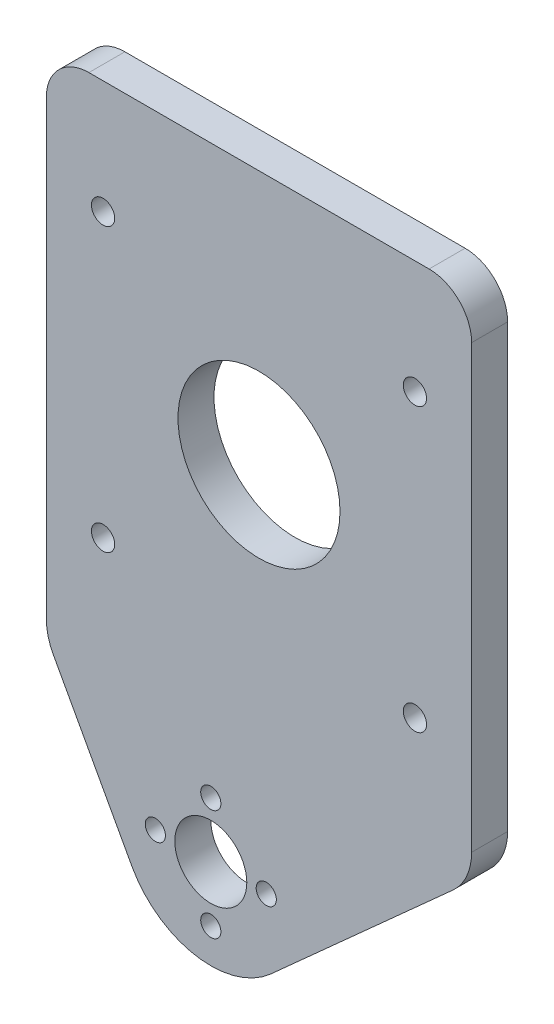
from build123d import *

# Parameters (mm, degrees)
SKETCH1_W           = 304.8
SKETCH1_H           = 89.8
SKETCH1_R           = 14.2875
SKETCH1_R_2         = 2.54
SKETCH1_R_3         = 17.145
BOSS_EXTRUDE1_DEPTH = 6.35
SKETCH2_W           = 114.9
SKETCH2_H           = 89.8
SKETCH2_R           = 2.54
SKETCH2_R_2         = 17.145
CUT_EXTRUDE1_DEPTH  = 10
SKETCH4_R           = 6.35
SKETCH4_R_2         = 1.778
BOSS_EXTRUDE2_DEPTH = 6.35
FILLET1_R           = 10
FILLET2_R           = 7.5
SKETCH7_R           = 2.05
CUT_EXTRUDE2_DEPTH  = 10


with BuildPart() as part:
    # Sketch1 → Boss-Extrude1 (new body)
    with BuildSketch(Plane.XY):
        with Locations((152.4, 44.9)):
            Rectangle(SKETCH1_W, SKETCH1_H)
        with Locations((152.4, 44.9)):
            Circle(SKETCH1_R, mode=Mode.SUBTRACT)
        with Locations((109.401585406, 62.859439014)):
            Circle(SKETCH1_R_2, mode=Mode.SUBTRACT)
        with Locations((109.399439014, 26.938414594)):
            Circle(SKETCH1_R_2, mode=Mode.SUBTRACT)
        with Locations((73.478414594, 26.940560986)):
            Circle(SKETCH1_R_2, mode=Mode.SUBTRACT)
        with Locations((73.480560986, 62.861585406)):
            Circle(SKETCH1_R_2, mode=Mode.SUBTRACT)
        with Locations((91.44, 44.9)):
            Circle(SKETCH1_R_3, mode=Mode.SUBTRACT)
        with Locations((195.400560986, 62.861585406)):
            Circle(SKETCH1_R_2, mode=Mode.SUBTRACT)
        with Locations((231.321585406, 62.859439014)):
            Circle(SKETCH1_R_2, mode=Mode.SUBTRACT)
        with Locations((231.319439014, 26.938414594)):
            Circle(SKETCH1_R_2, mode=Mode.SUBTRACT)
        with Locations((195.398414594, 26.940560986)):
            Circle(SKETCH1_R_2, mode=Mode.SUBTRACT)
        with Locations((213.36, 44.9)):
            Circle(SKETCH1_R_3, mode=Mode.SUBTRACT)
    extrude(amount=BOSS_EXTRUDE1_DEPTH)

    # Sketch2 → Cut-Extrude1 (cut)
    with BuildSketch(Plane.XY.offset(6.35)):
        with Locations((247.35, 44.9)):
            Rectangle(SKETCH2_W, SKETCH2_H)
        with Locations((195.398414594, 26.940560986)):
            Circle(SKETCH2_R, mode=Mode.SUBTRACT)
        with Locations((231.319439014, 26.938414594)):
            Circle(SKETCH2_R, mode=Mode.SUBTRACT)
        with Locations((213.36, 44.9)):
            Circle(SKETCH2_R_2, mode=Mode.SUBTRACT)
        with Locations((195.400560986, 62.861585406)):
            Circle(SKETCH2_R, mode=Mode.SUBTRACT)
        with Locations((231.321585406, 62.859439014)):
            Circle(SKETCH2_R, mode=Mode.SUBTRACT)
        with Locations((57.45, 44.9)):
            Rectangle(SKETCH2_W, SKETCH2_H)
        with Locations((73.478414594, 26.940560986)):
            Circle(SKETCH2_R, mode=Mode.SUBTRACT)
        with Locations((109.399439014, 26.938414594)):
            Circle(SKETCH2_R, mode=Mode.SUBTRACT)
        with Locations((91.44, 44.9)):
            Circle(SKETCH2_R_2, mode=Mode.SUBTRACT)
        with Locations((73.480560986, 62.861585406)):
            Circle(SKETCH2_R, mode=Mode.SUBTRACT)
        with Locations((109.401585406, 62.859439014)):
            Circle(SKETCH2_R, mode=Mode.SUBTRACT)
    extrude(amount=-CUT_EXTRUDE1_DEPTH, mode=Mode.SUBTRACT)

    # Sketch4 → Boss-Extrude2 (add)
    with BuildSketch(Plane.XY.offset(6.35)):
        with BuildLine():
            Line((189.9, 0), (154.512001483, -31.80682216))
            ThreePointArc((154.512001483, -31.80682216), (141.221457874, -35.647397134), (129.96508312, -27.604848226))
            Line((129.96508312, -27.604848226), (114.9, 0))
            Line((114.9, 0), (189.9, 0))
        make_face()
        with Locations((143.9, -20)):
            Circle(SKETCH4_R, mode=Mode.SUBTRACT)
        with Locations((143.9, -29.779)):
            Circle(SKETCH4_R_2, mode=Mode.SUBTRACT)
        with Locations((134.121, -20)):
            Circle(SKETCH4_R_2, mode=Mode.SUBTRACT)
        with Locations((153.679, -20)):
            Circle(SKETCH4_R_2, mode=Mode.SUBTRACT)
        with Locations((143.9, -10.221)):
            Circle(SKETCH4_R_2, mode=Mode.SUBTRACT)
    extrude(amount=-BOSS_EXTRUDE2_DEPTH)

    # Fillet1
    fillet1_edges = [part.edges().sort_by_distance(p)[0] for p in [
        (189.9, 0, 3.175),
        (114.9, 0, 3.175),
    ]]
    fillet(fillet1_edges, radius=FILLET1_R)

    # Fillet2
    fillet2_edges = [part.edges().sort_by_distance(p)[0] for p in [
        (114.9, 89.8, 3.175),
        (189.9, 89.8, 3.175),
    ]]
    fillet(fillet2_edges, radius=FILLET2_R)

    # Sketch7 → Cut-Extrude2 (cut)
    with BuildSketch(Plane.XY.offset(6.35)):
        with Locations((179.9, 69.8)):
            Circle(SKETCH7_R)
        with Locations((124.9, 69.8)):
            Circle(SKETCH7_R)
        with Locations((124.9, 20)):
            Circle(SKETCH7_R)
        with Locations((179.9, 20)):
            Circle(SKETCH7_R)
    extrude(amount=-CUT_EXTRUDE2_DEPTH, mode=Mode.SUBTRACT)


solid = part.part
